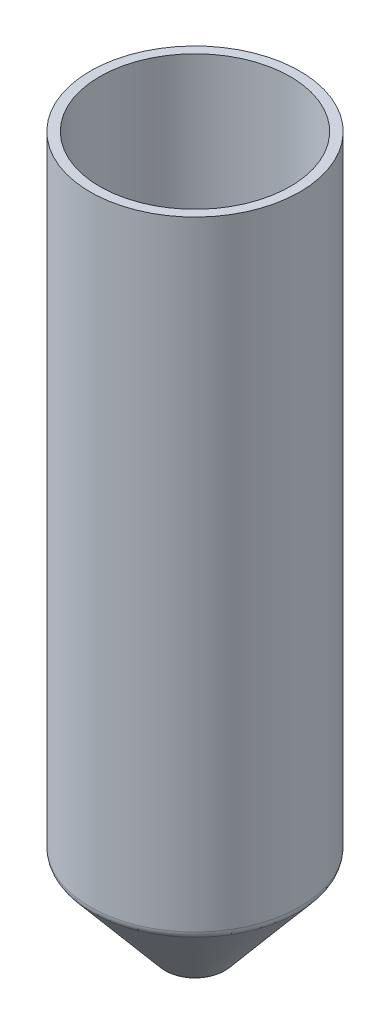
from build123d import *

# Parameters (mm, degrees)
FILLET1_R = 2
FILLET3_R = 2


with BuildPart() as part:
    # Sketch1 → Revolve1 (revolve)
    with BuildSketch(Plane.XY):
        Polygon((-22, 0), (-22, -130.727940469), (-5.828821955, -150), (-3.218007376, -150), (-20, -130), (-20, 0), align=None)
    revolve(axis=Axis((0, 0, 0), (0, -1, 0)))

    # Fillet1
    fillet1_edges = [part.edges().sort_by_distance(p)[0] for p in [
        (22, -130.727940469, 0),
    ]]
    fillet(fillet1_edges, radius=FILLET1_R)

    # Fillet3
    fillet3_edges = [part.edges().sort_by_distance(p)[0] for p in [
        (5.828821955, -150, 0),
    ]]
    fillet(fillet3_edges, radius=FILLET3_R)


solid = part.part
